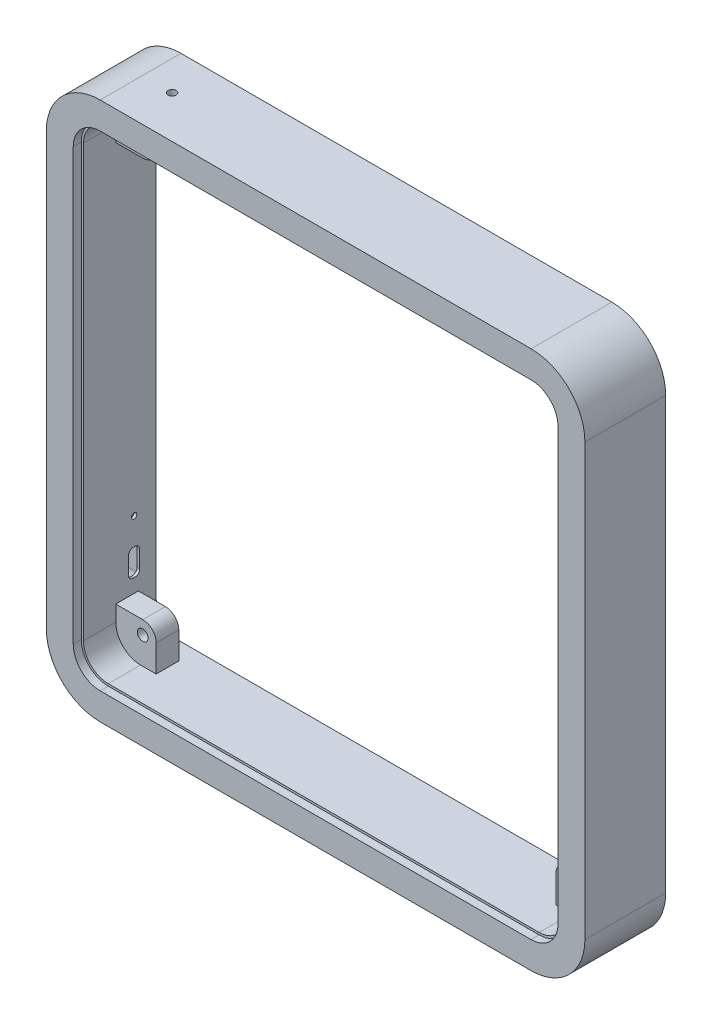
from build123d import *

# Parameters (mm, degrees)
SKETCH2_W                = 200
SKETCH2_H                = 200
BOSS_EXTRUDE1_DEPTH      = 30
FILLET1_R                = 20
CUT_EXTRUDE1_DEPTH       = 3
CUT_EXTRUDE2_DEPTH       = 28
SKETCH6_W                = 15
SKETCH6_H                = 15
BOSS_EXTRUDE4_DEPTH      = 15
FILLET2_R                = 5
F_4_0_4_DIAMETER_HOLE1_D = 4
CUT_EXTRUDE3_DEPTH       = 6.6
CUT_EXTRUDE4_REACH       = 202
SKETCH11_R               = 1.5
SKETCH15_R               = 1
CUT_EXTRUDE5_DEPTH       = 11.8
CUT_EXTRUDE7_DEPTH       = 9.8
FILLET3_R                = 1


with BuildPart() as part:
    # Sketch2 → Boss-Extrude1 (new body)
    with BuildSketch(Plane.XY):
        Rectangle(SKETCH2_W, SKETCH2_H)
    extrude(amount=BOSS_EXTRUDE1_DEPTH)

    # Fillet1
    fillet1_edges = [part.edges().sort_by_distance(p)[0] for p in [
        (100, -100, 15),
        (-100, -100, 15),
        (-100, 100, 15),
        (100, 100, 15),
    ]]
    fillet(fillet1_edges, radius=FILLET1_R)

    # Sketch3 → Cut-Extrude1 (cut)
    with BuildSketch(Plane.XY.offset(30)):
        with BuildLine():
            Line((-90, 80), (-90, -80))
            ThreePointArc((-90, -80), (-87.071067812, -87.071067812), (-80, -90))
            Line((-80, -90), (80, -90))
            ThreePointArc((80, -90), (87.071067812, -87.071067812), (90, -80))
            Line((90, -80), (90, 80))
            ThreePointArc((90, 80), (87.071067812, 87.071067812), (80, 90))
            Line((80, 90), (-80, 90))
            ThreePointArc((-80, 90), (-87.071067812, 87.071067812), (-90, 80))
        make_face()
    extrude(amount=-CUT_EXTRUDE1_DEPTH, mode=Mode.SUBTRACT)

    # Sketch4 → Cut-Extrude2 (cut, through all)
    with BuildSketch(Plane.XY.offset(27)):
        with BuildLine():
            Line((-89.2, 80), (-89.2, -80))
            ThreePointArc((-89.2, -80), (-86.505382387, -86.505382387), (-80, -89.2))
            Line((-80, -89.2), (80, -89.2))
            ThreePointArc((80, -89.2), (86.505382387, -86.505382387), (89.2, -80))
            Line((89.2, -80), (89.2, 80))
            ThreePointArc((89.2, 80), (86.505382387, 86.505382387), (80, 89.2))
            Line((80, 89.2), (-80, 89.2))
            ThreePointArc((-80, 89.2), (-86.505382387, 86.505382387), (-89.2, 80))
        make_face()
    extrude(amount=-CUT_EXTRUDE2_DEPTH, mode=Mode.SUBTRACT)

    # Sketch6 → Boss-Extrude4 (add)
    with BuildSketch(Plane(origin=(0, 0, 0), x_dir=(-1, 0, 0), z_dir=(0, 0, -1))):
        with Locations((-81.7, -81.7)):
            Rectangle(SKETCH6_W, SKETCH6_H)
        with Locations((-81.7, 81.7)):
            Rectangle(SKETCH6_W, SKETCH6_H)
        with Locations((81.7, 81.7)):
            Rectangle(SKETCH6_W, SKETCH6_H)
        with Locations((81.7, -81.7)):
            Rectangle(SKETCH6_W, SKETCH6_H)
    extrude(amount=-BOSS_EXTRUDE4_DEPTH)

    # Fillet2
    fillet2_edges = [part.edges().sort_by_distance(p)[0] for p in [
        (74.2, 74.2, 7.5),
        (-74.2, 74.2, 7.5),
        (-74.2, -74.2, 7.5),
        (74.2, -74.2, 7.5),
    ]]
    fillet(fillet2_edges, radius=FILLET2_R)

    # Ø4.0 (4) Diameter Hole1 (through all)
    with Locations(Plane(origin=(0, 0, 0), x_dir=(-1, 0, 0), z_dir=(0, 0, -1))):
        with Locations((-79.2, 79.2), (79.2, 79.2), (-79.2, -79.2), (79.2, -79.2)):
            Hole(F_4_0_4_DIAMETER_HOLE1_D / 2)

    # Sketch10 → Cut-Extrude3 (cut)
    with BuildSketch(Plane(origin=(0, 0, 0), x_dir=(-1, 0, 0), z_dir=(0, 0, -1))):
        with BuildLine():
            Line((89.2, -80), (89.2, 80))
            ThreePointArc((89.2, 80), (86.505382387, 86.505382387), (80, 89.2))
            Line((80, 89.2), (-80, 89.2))
            ThreePointArc((-80, 89.2), (-86.505382387, 86.505382387), (-89.2, 80))
            Line((-89.2, 80), (-89.2, -80))
            ThreePointArc((-89.2, -80), (-86.505382387, -86.505382387), (-80, -89.2))
            Line((-80, -89.2), (80, -89.2))
            ThreePointArc((80, -89.2), (86.505382387, -86.505382387), (89.2, -80))
        make_face()
    extrude(amount=-CUT_EXTRUDE3_DEPTH, mode=Mode.SUBTRACT)

    # Sketch11 → Cut-Extrude4 (cut, up to next)
    with BuildSketch(Plane(origin=(0, 100, 0), x_dir=(1, 0, 0), z_dir=(0, 1, 0)), mode=Mode.PRIVATE) as cut_extrude4_sk1:
        with Locations((-68.95500318, -14.324851484)):
            Circle(SKETCH11_R)
    cut_extrude4_tool1 = extrude(cut_extrude4_sk1.sketch, amount=-CUT_EXTRUDE4_REACH, mode=Mode.PRIVATE) & part.part
    add(cut_extrude4_tool1.solids().sort_by_distance((-68.955003, 100, 14.324851))[0], mode=Mode.SUBTRACT)

    # Sketch15 → Cut-Extrude5 (cut, through all)
    with BuildSketch(Plane(origin=(-89.2, 0, 0), x_dir=(0, 0, -1), z_dir=(1, 0, 0))):
        with Locations((-8.179999988, -49.23845191)):
            Circle(SKETCH15_R)
        with BuildLine():
            Line((-6.1, -64.178451904), (-6.1, -64.148451912))
            Line((-6.1, -64.148451912), (-6.1, -60.988451904))
            ThreePointArc((-6.1, -60.988451904), (-6.237016841, -60.299621726), (-6.627207794, -59.715659698))
            ThreePointArc((-6.627207794, -59.715659698), (-7.211170067, -59.325468644), (-7.90000053, -59.188451904))
            Line((-7.90000053, -59.188451904), (-8.46, -59.188451904))
            ThreePointArc((-8.46, -59.188451904), (-9.148830178, -59.325468746), (-9.732792206, -59.715659698))
            ThreePointArc((-9.732792206, -59.715659698), (-10.122983159, -60.299621726), (-10.26, -60.988451904))
            Line((-10.26, -60.988451904), (-10.26, -67.338451904))
            ThreePointArc((-10.26, -67.338451904), (-10.122983159, -68.027282082), (-9.732792205, -68.611244109))
            ThreePointArc((-9.732792205, -68.611244109), (-9.148830178, -69.001435061), (-8.46, -69.138451901))
            Line((-8.46, -69.138451901), (-7.900000051, -69.138451901))
            ThreePointArc((-7.900000051, -69.138451901), (-7.211169847, -69.001435069), (-6.627207798, -68.611244107))
            ThreePointArc((-6.627207798, -68.611244107), (-6.237016846, -68.02728208), (-6.100000002, -67.338451904))
            Line((-6.100000002, -67.338451904), (-6.1, -64.178451904))
        make_face()
    extrude(amount=-CUT_EXTRUDE5_DEPTH, mode=Mode.SUBTRACT)

    # Sketch17 → Cut-Extrude7 (cut)
    with BuildSketch(Plane.ZY.offset(100)):
        with BuildLine():
            Line((15.061316978, -39.847521487), (7.5, -39.847521487))
            ThreePointArc((7.5, -39.847521487), (3.964466094, -41.311987581), (2.5, -44.847521487))
            Line((2.5, -44.847521487), (2.5, -72.5))
            ThreePointArc((2.5, -72.5), (3.964466094, -76.035533906), (7.5, -77.5))
            Line((7.5, -77.5), (15.061316978, -77.5))
            ThreePointArc((15.061316978, -77.5), (18.596850884, -76.035533906), (20.061316978, -72.5))
            Line((20.061316978, -72.5), (20.061316978, -44.847521487))
            ThreePointArc((20.061316978, -44.847521487), (18.596850884, -41.311987581), (15.061316978, -39.847521487))
        make_face()
    extrude(amount=-CUT_EXTRUDE7_DEPTH, mode=Mode.SUBTRACT)

    # Fillet3
    fillet3_edges = [part.edges().sort_by_distance(p)[0] for p in [
        (-100, -41.311987581, 3.964466094),
        (-100, -58.673760744, 2.5),
        (-100, -76.035533906, 3.964466094),
        (-100, -77.5, 11.280658489),
        (-100, -76.035533906, 18.596850884),
        (-100, -58.673760744, 20.061316978),
        (-100, -41.311987581, 18.596850884),
        (-100, -39.847521487, 11.280658489),
        (-90.2, -41.311987581, 3.964466094),
        (-90.2, -39.847521487, 11.280658489),
        (-90.2, -41.311987581, 18.596850884),
        (-90.2, -58.673760744, 20.061316978),
        (-90.2, -76.035533906, 18.596850884),
        (-90.2, -77.5, 11.280658489),
        (-90.2, -76.035533906, 3.964466094),
        (-90.2, -58.673760744, 2.5),
    ]]
    fillet(fillet3_edges, radius=FILLET3_R)


solid = part.part
